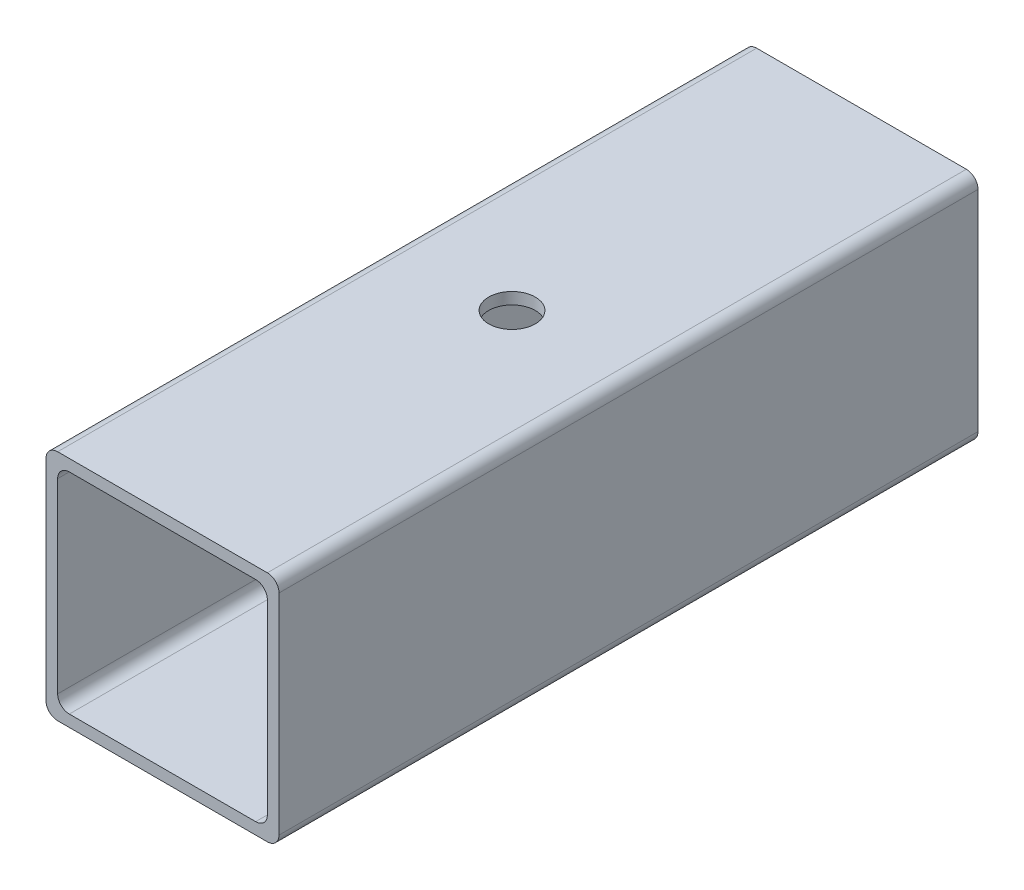
from build123d import *

# Parameters (mm, degrees)
SKETCH1_W               = 60
SKETCH1_H               = 60
SKETCH1_W_2             = 54
SKETCH1_H_2             = 54
BOSS_EXTRUDE1_DEPTH     = 180
FILLET1_R               = 3
SKETCH2_R               = 6
CUT_EXTRUDE1_DEPTH      = 31
CUT_EXTRUDE1_DEPTH_BACK = 31


with BuildPart() as part:
    # Sketch1 → Boss-Extrude1 (new body)
    with BuildSketch(Plane.XY):
        Rectangle(SKETCH1_W, SKETCH1_H)
        Rectangle(SKETCH1_W_2, SKETCH1_H_2, mode=Mode.SUBTRACT)
    extrude(amount=BOSS_EXTRUDE1_DEPTH)

    # Fillet1
    fillet1_edges = [part.edges().sort_by_distance(p)[0] for p in [
        (27, -27, 90),
        (27, 27, 90),
        (-27, 27, 90),
        (-27, -27, 90),
        (30, -30, 90),
        (-30, -30, 90),
        (-30, 30, 90),
        (30, 30, 90),
    ]]
    fillet(fillet1_edges, radius=FILLET1_R)

    # Sketch2 → Cut-Extrude1 (cut, two sides)
    with BuildSketch(Plane(origin=(0, 0, 0), x_dir=(1, 0, 0), z_dir=(0, 1, 0))) as cut_extrude1_sk:
        with Locations((0, -90)):
            Circle(SKETCH2_R)
    extrude(amount=CUT_EXTRUDE1_DEPTH, mode=Mode.SUBTRACT)
    extrude(cut_extrude1_sk.sketch, amount=-CUT_EXTRUDE1_DEPTH_BACK, mode=Mode.SUBTRACT)


solid = part.part
